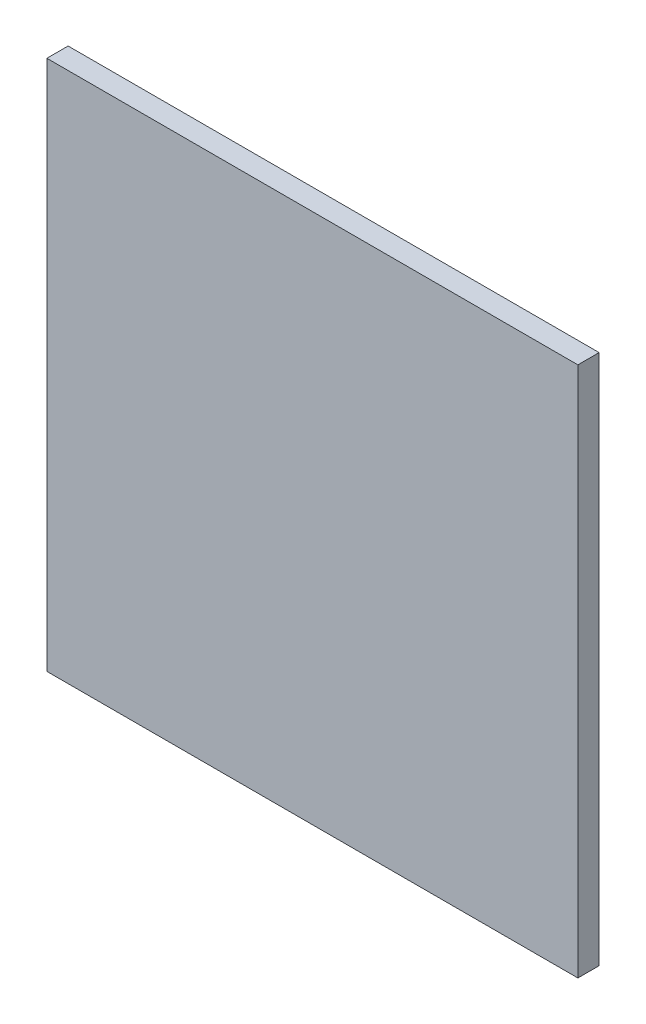
from build123d import *

# Parameters (mm, degrees)
SKETCH1_W           = 25
SKETCH1_H           = 25
BOSS_EXTRUDE1_DEPTH = 1


with BuildPart() as part:
    # Sketch1 → Boss-Extrude1 (new body)
    with BuildSketch(Plane.XY):
        Rectangle(SKETCH1_W, SKETCH1_H)
    extrude(amount=BOSS_EXTRUDE1_DEPTH)


solid = part.part
